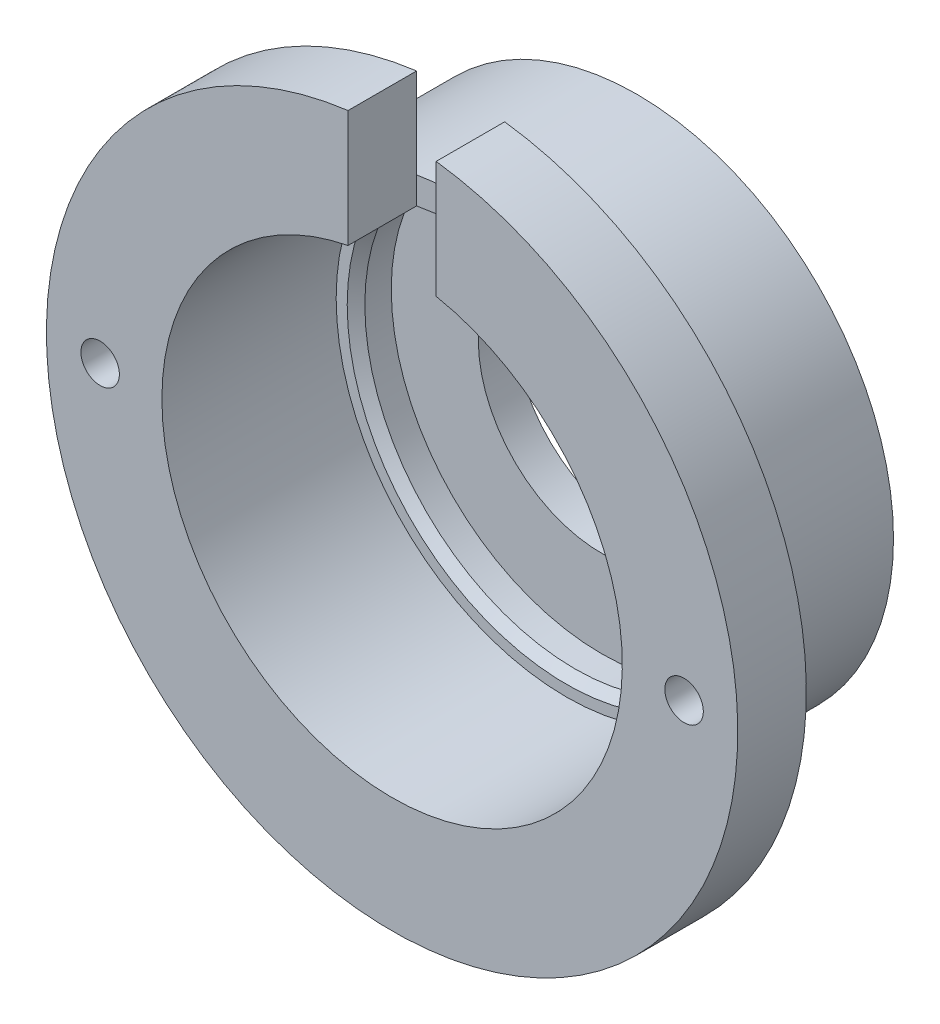
from build123d import *

# Parameters (mm, degrees)
SKETCH1_W          = 12.617819502
SKETCH1_H          = 2
SKETCH1_W_2        = 6.5532
SKETCH1_H_2        = 9.89
SKETCH2_R          = 26.652766262
SKETCH2_R_2        = 14.565
CUT_EXTRUDE1_DEPTH = 10
SKETCH4_R          = 1.0922
CUT_EXTRUDE2_DEPTH = 4.89
CHAMFER1_SIZE      = 0.5
CUT_EXTRUDE3_DEPTH = 10
SKETCH6_W          = 5
SKETCH6_H          = 3.89
CUT_EXTRUDE4_DEPTH = 10


with BuildPart() as part:
    # Sketch1 → Revolve1 (revolve)
    with BuildSketch(Plane(origin=(0, 0, 0), x_dir=(1, 0, 0), z_dir=(0, 1, 0))):
        with Locations((-13.308909751, 3.700473465)):
            Rectangle(SKETCH1_W, SKETCH1_H)
        Polygon((-11.938, 2.700473465), (-19.617819502, 2.700473465), (-19.617819502, 0.700473465), (-13.064619502, 0.700473465), (-11.938, 0.700473465), align=None)
        with Locations((-16.341219502, -4.244526535)):
            Rectangle(SKETCH1_W_2, SKETCH1_H_2)
    revolve(axis=Axis((0, 0, -25.411285606), (0, 0, 1)))

    # Sketch2 → Cut-Extrude1 (cut)
    with BuildSketch(Plane(origin=(0, 0, -4.700473465), x_dir=(-1, 0, 0), z_dir=(0, 0, -1))):
        Circle(SKETCH2_R)
        Circle(SKETCH2_R_2, mode=Mode.SUBTRACT)
    extrude(amount=-CUT_EXTRUDE1_DEPTH, mode=Mode.SUBTRACT)

    # Sketch4 → Cut-Extrude2 (cut, through all)
    with BuildSketch(Plane(origin=(0, 0, 5.299526535), x_dir=(-1, 0, 0), z_dir=(0, 0, -1))):
        with Locations((16.57, 0)):
            Circle(SKETCH4_R)
        with Locations((-16.57, 0)):
            Circle(SKETCH4_R)
    extrude(amount=-CUT_EXTRUDE2_DEPTH, mode=Mode.SUBTRACT)

    # Chamfer1
    chamfer1_edges = [part.edges().sort_by_distance(p)[0] for p in [
        (11.938, 0, -0.700473465),
    ]]
    chamfer(chamfer1_edges, length=CHAMFER1_SIZE)

    # Sketch5 → Cut-Extrude3 (cut)
    with BuildSketch(Plane(origin=(0, 0, 5.299526535), x_dir=(-1, 0, 0), z_dir=(0, 0, -1))):
        with BuildLine():
            Line((0, 19.617819502), (0, 14.565))
            Line((0, 14.565), (2.5, 14.565))
            Line((2.5, 14.565), (2.5, 19.457873522))
            ThreePointArc((2.5, 19.457873522), (1.252555659, 19.577792172), (0, 19.617819502))
        make_face()
        with BuildLine():
            Line((-2.5, 19.457873522), (-2.5, 14.565))
            Line((-2.5, 14.565), (0, 14.565))
            Line((0, 14.565), (0, 19.617819502))
            ThreePointArc((0, 19.617819502), (-1.252555659, 19.577792172), (-2.5, 19.457873522))
        make_face()
    extrude(amount=-CUT_EXTRUDE3_DEPTH, mode=Mode.SUBTRACT)

    # Sketch6 → Cut-Extrude4 (cut)
    with BuildSketch(Plane(origin=(0, 14.565, 0), x_dir=(1, 0, 0), z_dir=(0, 1, 0))):
        with Locations((0, -7.244526535)):
            Rectangle(SKETCH6_W, SKETCH6_H)
    extrude(amount=-CUT_EXTRUDE4_DEPTH, mode=Mode.SUBTRACT)


solid = part.part
